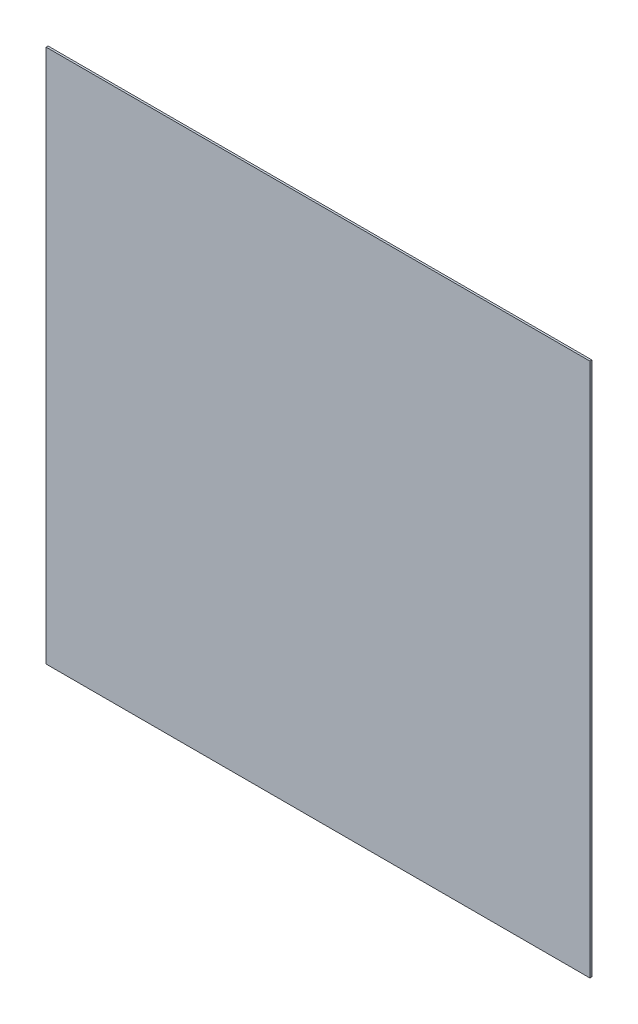
from build123d import *

# Parameters (mm, degrees)
SKETCH1_W           = 548.48125
SKETCH1_H           = 538.95625
BOSS_EXTRUDE1_DEPTH = 2


with BuildPart() as part:
    # Sketch1 → Boss-Extrude1 (new body)
    with BuildSketch(Plane.XY):
        Rectangle(SKETCH1_W, SKETCH1_H)
    extrude(amount=BOSS_EXTRUDE1_DEPTH)


solid = part.part
